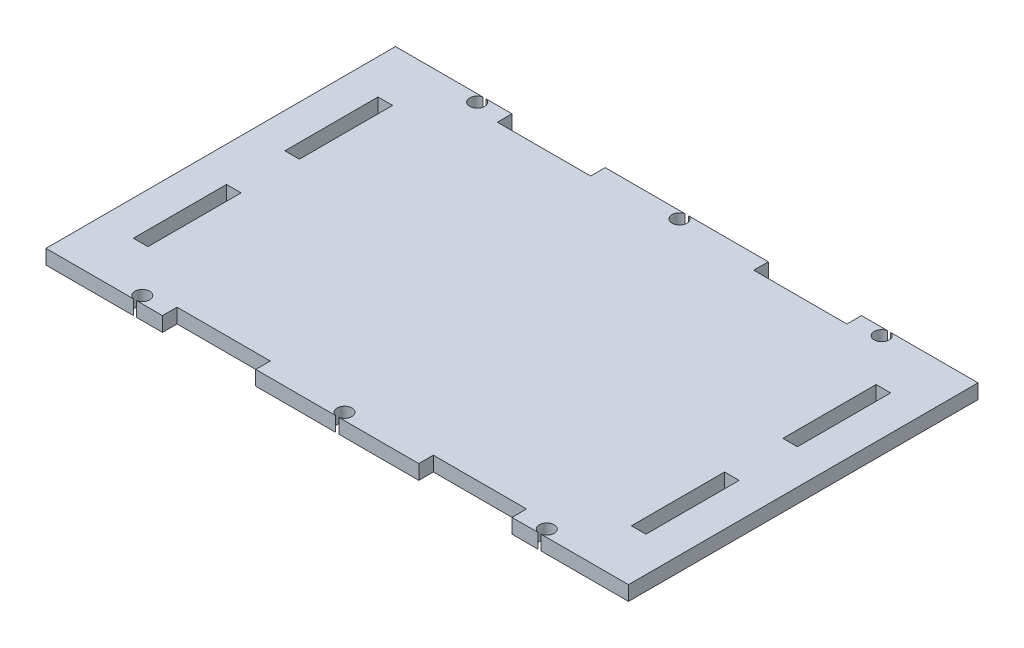
from build123d import *

# Parameters (mm, degrees)
SKETCH1_W           = 127
SKETCH1_H           = 76.2
BOSS_EXTRUDE1_DEPTH = 3.175
SKETCH2_W           = 3.175
SKETCH2_H           = 20.32
CUT_EXTRUDE1_DEPTH  = 3.175
SKETCH3_W           = 20.32
SKETCH3_H           = 3.175
CUT_EXTRUDE2_DEPTH  = 3.175
SKETCH4_R           = 1.6256
CUT_EXTRUDE3_DEPTH  = 3.175


with BuildPart() as part:
    # Sketch1 → Boss-Extrude1 (new body)
    with BuildSketch(Plane(origin=(0, 0, 0), x_dir=(1, 0, 0), z_dir=(0, 1, 0))):
        Rectangle(SKETCH1_W, SKETCH1_H)
    extrude(amount=BOSS_EXTRUDE1_DEPTH)

    # Sketch2 → Cut-Extrude1 (cut)
    with BuildSketch(Plane(origin=(0, 3.175, 0), x_dir=(1, 0, 0), z_dir=(0, 1, 0))):
        with Locations((-54.2925, 16.51)):
            Rectangle(SKETCH2_W, SKETCH2_H)
        with Locations((-54.2925, -16.51)):
            Rectangle(SKETCH2_W, SKETCH2_H)
        with Locations((54.2925, -16.51)):
            Rectangle(SKETCH2_W, SKETCH2_H)
        with Locations((54.2925, 16.51)):
            Rectangle(SKETCH2_W, SKETCH2_H)
    extrude(amount=-CUT_EXTRUDE1_DEPTH, mode=Mode.SUBTRACT)

    # Sketch3 → Cut-Extrude2 (cut)
    with BuildSketch(Plane(origin=(0, 3.175, 0), x_dir=(1, 0, 0), z_dir=(0, 1, 0))):
        with Locations((-27.94, 36.5125)):
            Rectangle(SKETCH3_W, SKETCH3_H)
        with Locations((27.94, 36.5125)):
            Rectangle(SKETCH3_W, SKETCH3_H)
        with Locations((27.94, -36.5125)):
            Rectangle(SKETCH3_W, SKETCH3_H)
        with Locations((-27.94, -36.5125)):
            Rectangle(SKETCH3_W, SKETCH3_H)
    extrude(amount=-CUT_EXTRUDE2_DEPTH, mode=Mode.SUBTRACT)

    # Sketch4 → Cut-Extrude3 (cut)
    with BuildSketch(Plane(origin=(0, 3.175, 0), x_dir=(1, 0, 0), z_dir=(0, 1, 0))):
        with Locations((-44.0944, 36.5125)):
            Circle(SKETCH4_R)
        with Locations((0, 36.5125)):
            Circle(SKETCH4_R)
        with Locations((44.0944, 36.5125)):
            Circle(SKETCH4_R)
        with Locations((44.0944, -36.5125)):
            Circle(SKETCH4_R)
        with Locations((0, -36.5125)):
            Circle(SKETCH4_R)
        with Locations((-44.0944, -36.5125)):
            Circle(SKETCH4_R)
    extrude(amount=-CUT_EXTRUDE3_DEPTH, mode=Mode.SUBTRACT)


solid = part.part
